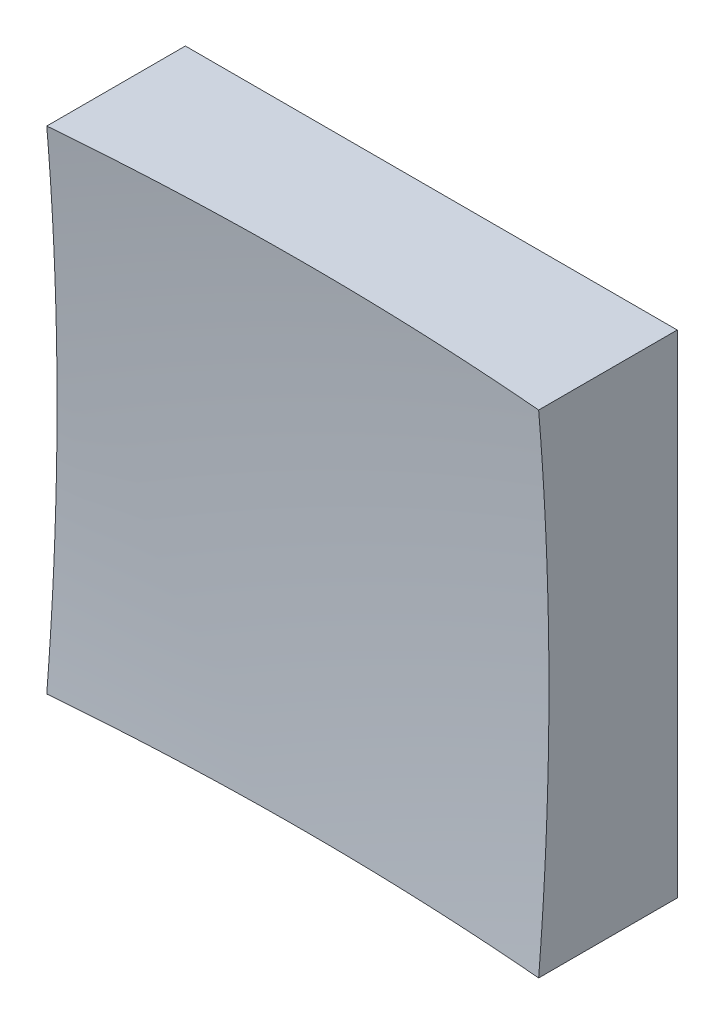
from build123d import *

# Parameters (mm, degrees)
SKETCH_1_W      = 25
SKETCH_1_H      = 25
EXTRUDE_1_DEPTH = 20


with BuildPart() as part:
    # 草图1 → 凸台-拉伸1 (new body)
    with BuildSketch(Plane.XY):
        Rectangle(SKETCH_1_W, SKETCH_1_H)
    extrude(amount=EXTRUDE_1_DEPTH)

    # 草图2 → 切除-旋转2 (revolve, cut)
    with BuildSketch(Plane(origin=(0, 0, 0), x_dir=(1, 0, 0), z_dir=(0, 1, 0))):
        with BuildLine():
            Line((146.226819272, -122.567720305), (0, -122.567720305))
            Line((0, -122.567720305), (0, -6))
            ThreePointArc((0, -6), (93.501759464, -38.70796712), (146.226819272, -122.567720305))
        make_face()
    revolve(axis=Axis((0, 0, 122.567720305), (0, 0, -1)), mode=Mode.SUBTRACT)


solid = part.part
